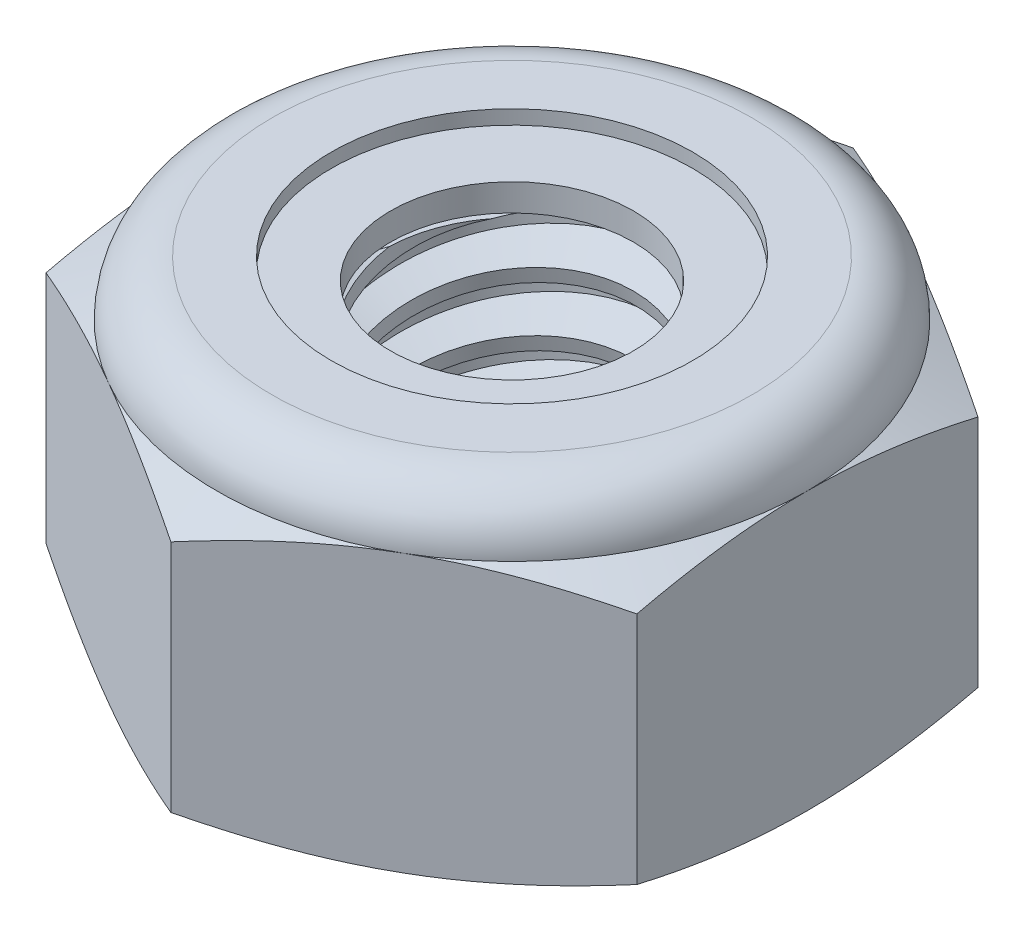
from build123d import *

# Parameters (mm, degrees)
EXTRUDE1_DEPTH      = 3.571875
SKETCH2_W           = 1.5875
SKETCH2_H           = 3.571875
LPATTERN1_COUNT     = 6
LPATTERN1_PITCH     = 0.635
LPATTERN1_COL_COUNT = 2
LPATTERN1_COL_PITCH = 0.635


with BuildPart() as part:
    # Sketch1 → Extrude1 (new body)
    with BuildSketch(Plane(origin=(0, 0, 0), x_dir=(1, 0, 0), z_dir=(0, 1, 0))):
        Polygon((0, 3.666174209), (-3.175, 1.833087105), (-3.175, -1.833087105), (0, -3.666174209), (3.175, -1.833087105), (3.175, 1.833087105), align=None)
    extrude(amount=EXTRUDE1_DEPTH)

    # Sketch4 → Cut-Revolve2 (revolve, cut)
    with BuildSketch(Plane(origin=(0, 0, 0), x_dir=(0, 0, -1), z_dir=(1, 0, 0))):
        Polygon((0, 3.571875), (1.5875, 3.571875), (1.304954178, 3.440121719), (1.304954178, 0.131753281), (1.5875, 0), (0, 0), align=None)
    revolve(axis=Axis((0, 3.571875, 0), (0, 1, 0)), mode=Mode.SUBTRACT)


with BuildPart() as body_2:
    # Sketch2 → Revolve1 (revolve)
    with BuildSketch(Plane(origin=(0, 0, 0), x_dir=(0, 0, -1), z_dir=(1, 0, 0))):
        with Locations((0.79375, 1.7859375)):
            Rectangle(SKETCH2_W, SKETCH2_H)
    revolve(axis=Axis((0, -1.5875, 0), (0, 1, 0)))

    # Sketch3 → Cut-Revolve1 (revolve, cut)
    with BuildSketch(Plane(origin=(0, 0, 0), x_dir=(0, 0, -1), z_dir=(1, 0, 0))):
        Polygon((1.603066718, 3.494041409), (1.712033746, 2.949206271), (1.336087614, 3.076384382), (1.304954178, 3.232051564), align=None)
    cut_revolve1 = revolve(axis=Axis((0, 3.571875, 0.136352241), (0, -0.980580676, -0.196116135)), mode=Mode.SUBTRACT)

    # LPattern1: Cut-Revolve1 ×6
    with Locations(*[(0, -i * LPATTERN1_PITCH, 0) for i in range(1, LPATTERN1_COUNT)]):
        add(cut_revolve1, mode=Mode.SUBTRACT)

    # LPattern1 col: Cut-Revolve1 ×2
    with Locations(*[(0, i * LPATTERN1_COL_PITCH, 0) for i in range(1, LPATTERN1_COL_COUNT)]):
        add(cut_revolve1, mode=Mode.SUBTRACT)


with BuildPart() as part_1:
    add(part.part)

    # Combine1: cut body 2
    add(body_2.part, mode=Mode.SUBTRACT)

    # Sketch5 → Cut-Revolve3 (revolve, cut)
    with BuildSketch(Plane(origin=(0, 0, 0), x_dir=(0, 0, -1), z_dir=(1, 0, 0))):
        with BuildLine():
            Line((0, 0), (3.175, 0))
            Line((3.175, 0), (3.666174209, 0.229038295))
            Line((3.666174209, 0.229038295), (3.666174209, 2.747524205))
            Line((3.666174209, 2.747524205), (3.175, 2.9765625))
            ThreePointArc((3.175, 2.9765625), (3.000637006, 3.397512006), (2.5796875, 3.571875))
            Line((2.5796875, 3.571875), (2.5796875, 4.841875))
            Line((2.5796875, 4.841875), (4.936174209, 4.841875))
            Line((4.936174209, 4.841875), (4.936174209, -1.27))
            Line((4.936174209, -1.27), (0, -1.27))
            Line((0, -1.27), (0, 0))
        make_face()
    revolve(axis=Axis((0, 0, 0), (0, 1, 0)), mode=Mode.SUBTRACT)

    # Sketch6 → Cut-Revolve4 (revolve, cut)
    with BuildSketch(Plane(origin=(0, 0, 0), x_dir=(0, 0, -1), z_dir=(1, 0, 0))):
        with BuildLine():
            Line((0, 2.9765625), (3.0226, 2.9765625))
            ThreePointArc((3.0226, 2.9765625), (2.892873932, 3.289748932), (2.5796875, 3.419475))
            Line((2.5796875, 3.419475), (1.942320839, 3.419475))
            Line((1.942320839, 3.419475), (1.942320839, 4.841875))
            Line((1.942320839, 4.841875), (0, 4.841875))
            Line((0, 4.841875), (0, 2.9765625))
        make_face()
    revolve(axis=Axis((0, 4.841875, 0), (0, 1, 0)), mode=Mode.SUBTRACT)


with BuildPart() as body_2_2:
    # Sketch7 → Revolve2 (revolve)
    with BuildSketch(Plane(origin=(0, 0, 0), x_dir=(0, 0, -1), z_dir=(1, 0, 0))):
        with BuildLine():
            Line((1.304954178, 3.0527625), (2.938395763, 3.0527625))
            ThreePointArc((2.938395763, 3.0527625), (2.810484559, 3.261537543), (2.5796875, 3.343275))
            Line((2.5796875, 3.343275), (1.304954178, 3.343275))
            Line((1.304954178, 3.343275), (1.304954178, 3.0527625))
        make_face()
    revolve(axis=Axis((0, 3.0527625, 0), (0, 1, 0)))


solid = Compound([part_1.part, body_2_2.part])
